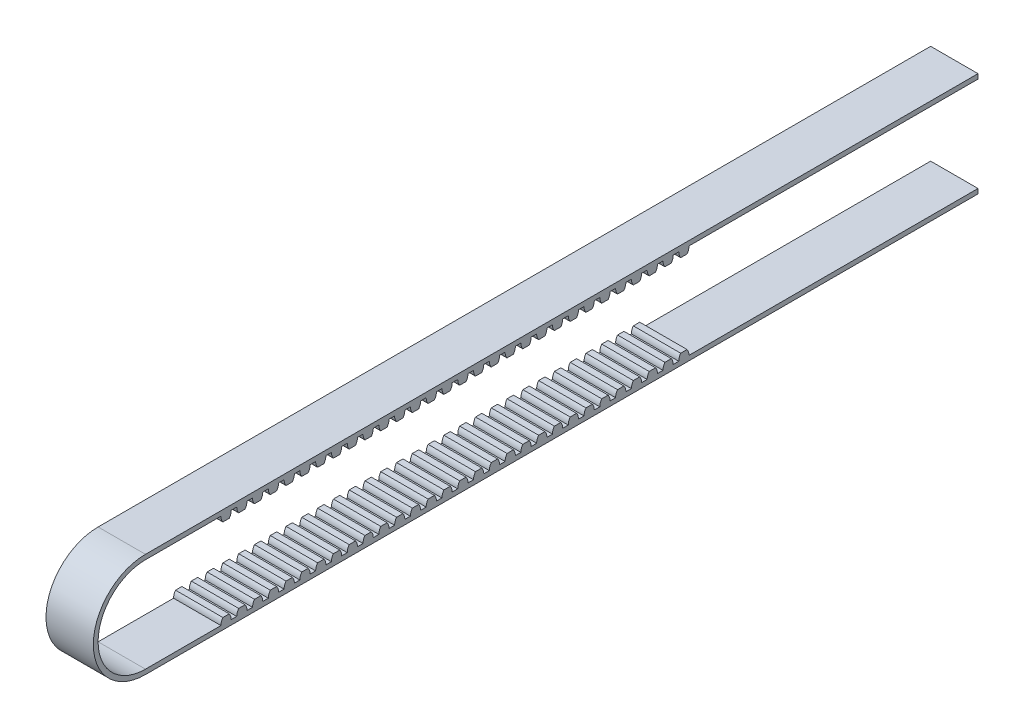
from build123d import *

# Parameters (mm, degrees)
SKETCH_1_W             = 6
SKETCH_1_H             = 0.6
EXTRUDE_1_DEPTH        = 100
EXTRUDE_2_DEPTH        = 6
PATTERN_LINEAR_1_COUNT = 30
PATTERN_LINEAR_1_PITCH = 2
EXTRUDE_3_DEPTH        = 6
MIRROR_1_COPY_1_DEPTH  = 6
MIRROR_1_COPY_2_DEPTH  = 6
MIRROR_1_COPY_3_DEPTH  = 6
MIRROR_1_COPY_4_DEPTH  = 6
MIRROR_1_COPY_5_DEPTH  = 6
MIRROR_1_COPY_6_DEPTH  = 6
MIRROR_1_COPY_7_DEPTH  = 6
MIRROR_1_COPY_8_DEPTH  = 6
MIRROR_1_COPY_9_DEPTH  = 6
MIRROR_1_COPY_10_DEPTH = 6
MIRROR_1_COPY_11_DEPTH = 6
MIRROR_1_COPY_12_DEPTH = 6
MIRROR_1_COPY_13_DEPTH = 6
MIRROR_1_COPY_14_DEPTH = 6
MIRROR_1_COPY_15_DEPTH = 6
MIRROR_1_COPY_16_DEPTH = 6
MIRROR_1_COPY_17_DEPTH = 6
MIRROR_1_COPY_18_DEPTH = 6
MIRROR_1_COPY_19_DEPTH = 6
MIRROR_1_COPY_20_DEPTH = 6
MIRROR_1_COPY_21_DEPTH = 6
MIRROR_1_COPY_22_DEPTH = 6
MIRROR_1_COPY_23_DEPTH = 6
MIRROR_1_COPY_24_DEPTH = 6
MIRROR_1_COPY_25_DEPTH = 6
MIRROR_1_COPY_26_DEPTH = 6
MIRROR_1_COPY_27_DEPTH = 6
MIRROR_1_COPY_28_DEPTH = 6
MIRROR_1_COPY_29_DEPTH = 6


with BuildPart() as part:
    # 草图1 → 凸台-拉伸1 (new body)
    with BuildSketch(Plane.XY):
        with Locations((3, 0.3)):
            Rectangle(SKETCH_1_W, SKETCH_1_H)
    extrude_1 = extrude(amount=EXTRUDE_1_DEPTH)

    # 草图2 → 凸台-拉伸2 (add)
    with BuildSketch(Plane(origin=(6, 0, 0), x_dir=(0, 0, -1), z_dir=(1, 0, 0))):
        with BuildLine():
            ThreePointArc((-95.914090338, 0), (-95.851247336, -0.399302595), (-95.668794088, -0.76))
            Line((-95.668794088, -0.76), (-94.859386588, -0.76))
            ThreePointArc((-94.859386588, -0.76), (-94.67693334, -0.399302595), (-94.614090338, 0))
            Line((-94.614090338, 0), (-95.914090338, 0))
        make_face()
    extrude_2 = extrude(amount=-EXTRUDE_2_DEPTH)

    # 阵列(线性)1: 凸台-拉伸2 ×30
    with Locations(*[(0, 0, -i * PATTERN_LINEAR_1_PITCH) for i in range(1, PATTERN_LINEAR_1_COUNT)]):
        add(extrude_2)

    # 草图3 → 凸台-拉伸3 (add)
    with BuildSketch(Plane(origin=(6, 0, 0), x_dir=(0, 0, -1), z_dir=(1, 0, 0))):
        with BuildLine():
            Line((-100, 0), (-105.478079639, 0))
            ThreePointArc((-105.478079639, 0), (-111.478079639, -6), (-105.478079639, -12))
            Line((-105.478079639, -12), (-93.443415231, -12))
            Line((-93.443415231, -12), (-93.443415231, -12.6))
            Line((-93.443415231, -12.6), (-105.478079639, -12.6))
            ThreePointArc((-105.478079639, -12.6), (-112.078079639, -6), (-105.478079639, 0.6))
            Line((-105.478079639, 0.6), (-100, 0.6))
            Line((-100, 0.6), (-100, 0))
        make_face()
    extrude_3 = extrude(amount=-EXTRUDE_3_DEPTH)

    # 镜向1: 凸台-拉伸3, 凸台-拉伸1, 凸台-拉伸2 across plane
    add(extrude_3.mirror(Plane.ZX.offset(-6)))
    add(extrude_1.mirror(Plane.ZX.offset(-6)))
    add(extrude_2.mirror(Plane.ZX.offset(-6)))

    # 镜向1 copy 1 sketch → 镜向1 copy 1 (add)
    with BuildSketch(Plane(origin=(6, -12, -2), x_dir=(0, 0, -1), z_dir=(1, 0, 0))):
        with BuildLine():
            ThreePointArc((-95.914090338, 0), (-95.851247336, 0.399302595), (-95.668794088, 0.76))
            Line((-95.668794088, 0.76), (-94.859386588, 0.76))
            ThreePointArc((-94.859386588, 0.76), (-94.67693334, 0.399302595), (-94.614090338, 0))
            Line((-94.614090338, 0), (-95.914090338, 0))
        make_face()
    extrude(amount=-MIRROR_1_COPY_1_DEPTH)

    # 镜向1 copy 2 sketch → 镜向1 copy 2 (add)
    with BuildSketch(Plane(origin=(6, -12, -4), x_dir=(0, 0, -1), z_dir=(1, 0, 0))):
        with BuildLine():
            ThreePointArc((-95.914090338, 0), (-95.851247336, 0.399302595), (-95.668794088, 0.76))
            Line((-95.668794088, 0.76), (-94.859386588, 0.76))
            ThreePointArc((-94.859386588, 0.76), (-94.67693334, 0.399302595), (-94.614090338, 0))
            Line((-94.614090338, 0), (-95.914090338, 0))
        make_face()
    extrude(amount=-MIRROR_1_COPY_2_DEPTH)

    # 镜向1 copy 3 sketch → 镜向1 copy 3 (add)
    with BuildSketch(Plane(origin=(6, -12, -6), x_dir=(0, 0, -1), z_dir=(1, 0, 0))):
        with BuildLine():
            ThreePointArc((-95.914090338, 0), (-95.851247336, 0.399302595), (-95.668794088, 0.76))
            Line((-95.668794088, 0.76), (-94.859386588, 0.76))
            ThreePointArc((-94.859386588, 0.76), (-94.67693334, 0.399302595), (-94.614090338, 0))
            Line((-94.614090338, 0), (-95.914090338, 0))
        make_face()
    extrude(amount=-MIRROR_1_COPY_3_DEPTH)

    # 镜向1 copy 4 sketch → 镜向1 copy 4 (add)
    with BuildSketch(Plane(origin=(6, -12, -8), x_dir=(0, 0, -1), z_dir=(1, 0, 0))):
        with BuildLine():
            ThreePointArc((-95.914090338, 0), (-95.851247336, 0.399302595), (-95.668794088, 0.76))
            Line((-95.668794088, 0.76), (-94.859386588, 0.76))
            ThreePointArc((-94.859386588, 0.76), (-94.67693334, 0.399302595), (-94.614090338, 0))
            Line((-94.614090338, 0), (-95.914090338, 0))
        make_face()
    extrude(amount=-MIRROR_1_COPY_4_DEPTH)

    # 镜向1 copy 5 sketch → 镜向1 copy 5 (add)
    with BuildSketch(Plane(origin=(6, -12, -10), x_dir=(0, 0, -1), z_dir=(1, 0, 0))):
        with BuildLine():
            ThreePointArc((-95.914090338, 0), (-95.851247336, 0.399302595), (-95.668794088, 0.76))
            Line((-95.668794088, 0.76), (-94.859386588, 0.76))
            ThreePointArc((-94.859386588, 0.76), (-94.67693334, 0.399302595), (-94.614090338, 0))
            Line((-94.614090338, 0), (-95.914090338, 0))
        make_face()
    extrude(amount=-MIRROR_1_COPY_5_DEPTH)

    # 镜向1 copy 6 sketch → 镜向1 copy 6 (add)
    with BuildSketch(Plane(origin=(6, -12, -12), x_dir=(0, 0, -1), z_dir=(1, 0, 0))):
        with BuildLine():
            ThreePointArc((-95.914090338, 0), (-95.851247336, 0.399302595), (-95.668794088, 0.76))
            Line((-95.668794088, 0.76), (-94.859386588, 0.76))
            ThreePointArc((-94.859386588, 0.76), (-94.67693334, 0.399302595), (-94.614090338, 0))
            Line((-94.614090338, 0), (-95.914090338, 0))
        make_face()
    extrude(amount=-MIRROR_1_COPY_6_DEPTH)

    # 镜向1 copy 7 sketch → 镜向1 copy 7 (add)
    with BuildSketch(Plane(origin=(6, -12, -14), x_dir=(0, 0, -1), z_dir=(1, 0, 0))):
        with BuildLine():
            ThreePointArc((-95.914090338, 0), (-95.851247336, 0.399302595), (-95.668794088, 0.76))
            Line((-95.668794088, 0.76), (-94.859386588, 0.76))
            ThreePointArc((-94.859386588, 0.76), (-94.67693334, 0.399302595), (-94.614090338, 0))
            Line((-94.614090338, 0), (-95.914090338, 0))
        make_face()
    extrude(amount=-MIRROR_1_COPY_7_DEPTH)

    # 镜向1 copy 8 sketch → 镜向1 copy 8 (add)
    with BuildSketch(Plane(origin=(6, -12, -16), x_dir=(0, 0, -1), z_dir=(1, 0, 0))):
        with BuildLine():
            ThreePointArc((-95.914090338, 0), (-95.851247336, 0.399302595), (-95.668794088, 0.76))
            Line((-95.668794088, 0.76), (-94.859386588, 0.76))
            ThreePointArc((-94.859386588, 0.76), (-94.67693334, 0.399302595), (-94.614090338, 0))
            Line((-94.614090338, 0), (-95.914090338, 0))
        make_face()
    extrude(amount=-MIRROR_1_COPY_8_DEPTH)

    # 镜向1 copy 9 sketch → 镜向1 copy 9 (add)
    with BuildSketch(Plane(origin=(6, -12, -18), x_dir=(0, 0, -1), z_dir=(1, 0, 0))):
        with BuildLine():
            ThreePointArc((-95.914090338, 0), (-95.851247336, 0.399302595), (-95.668794088, 0.76))
            Line((-95.668794088, 0.76), (-94.859386588, 0.76))
            ThreePointArc((-94.859386588, 0.76), (-94.67693334, 0.399302595), (-94.614090338, 0))
            Line((-94.614090338, 0), (-95.914090338, 0))
        make_face()
    extrude(amount=-MIRROR_1_COPY_9_DEPTH)

    # 镜向1 copy 10 sketch → 镜向1 copy 10 (add)
    with BuildSketch(Plane(origin=(6, -12, -20), x_dir=(0, 0, -1), z_dir=(1, 0, 0))):
        with BuildLine():
            ThreePointArc((-95.914090338, 0), (-95.851247336, 0.399302595), (-95.668794088, 0.76))
            Line((-95.668794088, 0.76), (-94.859386588, 0.76))
            ThreePointArc((-94.859386588, 0.76), (-94.67693334, 0.399302595), (-94.614090338, 0))
            Line((-94.614090338, 0), (-95.914090338, 0))
        make_face()
    extrude(amount=-MIRROR_1_COPY_10_DEPTH)

    # 镜向1 copy 11 sketch → 镜向1 copy 11 (add)
    with BuildSketch(Plane(origin=(6, -12, -22), x_dir=(0, 0, -1), z_dir=(1, 0, 0))):
        with BuildLine():
            ThreePointArc((-95.914090338, 0), (-95.851247336, 0.399302595), (-95.668794088, 0.76))
            Line((-95.668794088, 0.76), (-94.859386588, 0.76))
            ThreePointArc((-94.859386588, 0.76), (-94.67693334, 0.399302595), (-94.614090338, 0))
            Line((-94.614090338, 0), (-95.914090338, 0))
        make_face()
    extrude(amount=-MIRROR_1_COPY_11_DEPTH)

    # 镜向1 copy 12 sketch → 镜向1 copy 12 (add)
    with BuildSketch(Plane(origin=(6, -12, -24), x_dir=(0, 0, -1), z_dir=(1, 0, 0))):
        with BuildLine():
            ThreePointArc((-95.914090338, 0), (-95.851247336, 0.399302595), (-95.668794088, 0.76))
            Line((-95.668794088, 0.76), (-94.859386588, 0.76))
            ThreePointArc((-94.859386588, 0.76), (-94.67693334, 0.399302595), (-94.614090338, 0))
            Line((-94.614090338, 0), (-95.914090338, 0))
        make_face()
    extrude(amount=-MIRROR_1_COPY_12_DEPTH)

    # 镜向1 copy 13 sketch → 镜向1 copy 13 (add)
    with BuildSketch(Plane(origin=(6, -12, -26), x_dir=(0, 0, -1), z_dir=(1, 0, 0))):
        with BuildLine():
            ThreePointArc((-95.914090338, 0), (-95.851247336, 0.399302595), (-95.668794088, 0.76))
            Line((-95.668794088, 0.76), (-94.859386588, 0.76))
            ThreePointArc((-94.859386588, 0.76), (-94.67693334, 0.399302595), (-94.614090338, 0))
            Line((-94.614090338, 0), (-95.914090338, 0))
        make_face()
    extrude(amount=-MIRROR_1_COPY_13_DEPTH)

    # 镜向1 copy 14 sketch → 镜向1 copy 14 (add)
    with BuildSketch(Plane(origin=(6, -12, -28), x_dir=(0, 0, -1), z_dir=(1, 0, 0))):
        with BuildLine():
            ThreePointArc((-95.914090338, 0), (-95.851247336, 0.399302595), (-95.668794088, 0.76))
            Line((-95.668794088, 0.76), (-94.859386588, 0.76))
            ThreePointArc((-94.859386588, 0.76), (-94.67693334, 0.399302595), (-94.614090338, 0))
            Line((-94.614090338, 0), (-95.914090338, 0))
        make_face()
    extrude(amount=-MIRROR_1_COPY_14_DEPTH)

    # 镜向1 copy 15 sketch → 镜向1 copy 15 (add)
    with BuildSketch(Plane(origin=(6, -12, -30), x_dir=(0, 0, -1), z_dir=(1, 0, 0))):
        with BuildLine():
            ThreePointArc((-95.914090338, 0), (-95.851247336, 0.399302595), (-95.668794088, 0.76))
            Line((-95.668794088, 0.76), (-94.859386588, 0.76))
            ThreePointArc((-94.859386588, 0.76), (-94.67693334, 0.399302595), (-94.614090338, 0))
            Line((-94.614090338, 0), (-95.914090338, 0))
        make_face()
    extrude(amount=-MIRROR_1_COPY_15_DEPTH)

    # 镜向1 copy 16 sketch → 镜向1 copy 16 (add)
    with BuildSketch(Plane(origin=(6, -12, -32), x_dir=(0, 0, -1), z_dir=(1, 0, 0))):
        with BuildLine():
            ThreePointArc((-95.914090338, 0), (-95.851247336, 0.399302595), (-95.668794088, 0.76))
            Line((-95.668794088, 0.76), (-94.859386588, 0.76))
            ThreePointArc((-94.859386588, 0.76), (-94.67693334, 0.399302595), (-94.614090338, 0))
            Line((-94.614090338, 0), (-95.914090338, 0))
        make_face()
    extrude(amount=-MIRROR_1_COPY_16_DEPTH)

    # 镜向1 copy 17 sketch → 镜向1 copy 17 (add)
    with BuildSketch(Plane(origin=(6, -12, -34), x_dir=(0, 0, -1), z_dir=(1, 0, 0))):
        with BuildLine():
            ThreePointArc((-95.914090338, 0), (-95.851247336, 0.399302595), (-95.668794088, 0.76))
            Line((-95.668794088, 0.76), (-94.859386588, 0.76))
            ThreePointArc((-94.859386588, 0.76), (-94.67693334, 0.399302595), (-94.614090338, 0))
            Line((-94.614090338, 0), (-95.914090338, 0))
        make_face()
    extrude(amount=-MIRROR_1_COPY_17_DEPTH)

    # 镜向1 copy 18 sketch → 镜向1 copy 18 (add)
    with BuildSketch(Plane(origin=(6, -12, -36), x_dir=(0, 0, -1), z_dir=(1, 0, 0))):
        with BuildLine():
            ThreePointArc((-95.914090338, 0), (-95.851247336, 0.399302595), (-95.668794088, 0.76))
            Line((-95.668794088, 0.76), (-94.859386588, 0.76))
            ThreePointArc((-94.859386588, 0.76), (-94.67693334, 0.399302595), (-94.614090338, 0))
            Line((-94.614090338, 0), (-95.914090338, 0))
        make_face()
    extrude(amount=-MIRROR_1_COPY_18_DEPTH)

    # 镜向1 copy 19 sketch → 镜向1 copy 19 (add)
    with BuildSketch(Plane(origin=(6, -12, -38), x_dir=(0, 0, -1), z_dir=(1, 0, 0))):
        with BuildLine():
            ThreePointArc((-95.914090338, 0), (-95.851247336, 0.399302595), (-95.668794088, 0.76))
            Line((-95.668794088, 0.76), (-94.859386588, 0.76))
            ThreePointArc((-94.859386588, 0.76), (-94.67693334, 0.399302595), (-94.614090338, 0))
            Line((-94.614090338, 0), (-95.914090338, 0))
        make_face()
    extrude(amount=-MIRROR_1_COPY_19_DEPTH)

    # 镜向1 copy 20 sketch → 镜向1 copy 20 (add)
    with BuildSketch(Plane(origin=(6, -12, -40), x_dir=(0, 0, -1), z_dir=(1, 0, 0))):
        with BuildLine():
            ThreePointArc((-95.914090338, 0), (-95.851247336, 0.399302595), (-95.668794088, 0.76))
            Line((-95.668794088, 0.76), (-94.859386588, 0.76))
            ThreePointArc((-94.859386588, 0.76), (-94.67693334, 0.399302595), (-94.614090338, 0))
            Line((-94.614090338, 0), (-95.914090338, 0))
        make_face()
    extrude(amount=-MIRROR_1_COPY_20_DEPTH)

    # 镜向1 copy 21 sketch → 镜向1 copy 21 (add)
    with BuildSketch(Plane(origin=(6, -12, -42), x_dir=(0, 0, -1), z_dir=(1, 0, 0))):
        with BuildLine():
            ThreePointArc((-95.914090338, 0), (-95.851247336, 0.399302595), (-95.668794088, 0.76))
            Line((-95.668794088, 0.76), (-94.859386588, 0.76))
            ThreePointArc((-94.859386588, 0.76), (-94.67693334, 0.399302595), (-94.614090338, 0))
            Line((-94.614090338, 0), (-95.914090338, 0))
        make_face()
    extrude(amount=-MIRROR_1_COPY_21_DEPTH)

    # 镜向1 copy 22 sketch → 镜向1 copy 22 (add)
    with BuildSketch(Plane(origin=(6, -12, -44), x_dir=(0, 0, -1), z_dir=(1, 0, 0))):
        with BuildLine():
            ThreePointArc((-95.914090338, 0), (-95.851247336, 0.399302595), (-95.668794088, 0.76))
            Line((-95.668794088, 0.76), (-94.859386588, 0.76))
            ThreePointArc((-94.859386588, 0.76), (-94.67693334, 0.399302595), (-94.614090338, 0))
            Line((-94.614090338, 0), (-95.914090338, 0))
        make_face()
    extrude(amount=-MIRROR_1_COPY_22_DEPTH)

    # 镜向1 copy 23 sketch → 镜向1 copy 23 (add)
    with BuildSketch(Plane(origin=(6, -12, -46), x_dir=(0, 0, -1), z_dir=(1, 0, 0))):
        with BuildLine():
            ThreePointArc((-95.914090338, 0), (-95.851247336, 0.399302595), (-95.668794088, 0.76))
            Line((-95.668794088, 0.76), (-94.859386588, 0.76))
            ThreePointArc((-94.859386588, 0.76), (-94.67693334, 0.399302595), (-94.614090338, 0))
            Line((-94.614090338, 0), (-95.914090338, 0))
        make_face()
    extrude(amount=-MIRROR_1_COPY_23_DEPTH)

    # 镜向1 copy 24 sketch → 镜向1 copy 24 (add)
    with BuildSketch(Plane(origin=(6, -12, -48), x_dir=(0, 0, -1), z_dir=(1, 0, 0))):
        with BuildLine():
            ThreePointArc((-95.914090338, 0), (-95.851247336, 0.399302595), (-95.668794088, 0.76))
            Line((-95.668794088, 0.76), (-94.859386588, 0.76))
            ThreePointArc((-94.859386588, 0.76), (-94.67693334, 0.399302595), (-94.614090338, 0))
            Line((-94.614090338, 0), (-95.914090338, 0))
        make_face()
    extrude(amount=-MIRROR_1_COPY_24_DEPTH)

    # 镜向1 copy 25 sketch → 镜向1 copy 25 (add)
    with BuildSketch(Plane(origin=(6, -12, -50), x_dir=(0, 0, -1), z_dir=(1, 0, 0))):
        with BuildLine():
            ThreePointArc((-95.914090338, 0), (-95.851247336, 0.399302595), (-95.668794088, 0.76))
            Line((-95.668794088, 0.76), (-94.859386588, 0.76))
            ThreePointArc((-94.859386588, 0.76), (-94.67693334, 0.399302595), (-94.614090338, 0))
            Line((-94.614090338, 0), (-95.914090338, 0))
        make_face()
    extrude(amount=-MIRROR_1_COPY_25_DEPTH)

    # 镜向1 copy 26 sketch → 镜向1 copy 26 (add)
    with BuildSketch(Plane(origin=(6, -12, -52), x_dir=(0, 0, -1), z_dir=(1, 0, 0))):
        with BuildLine():
            ThreePointArc((-95.914090338, 0), (-95.851247336, 0.399302595), (-95.668794088, 0.76))
            Line((-95.668794088, 0.76), (-94.859386588, 0.76))
            ThreePointArc((-94.859386588, 0.76), (-94.67693334, 0.399302595), (-94.614090338, 0))
            Line((-94.614090338, 0), (-95.914090338, 0))
        make_face()
    extrude(amount=-MIRROR_1_COPY_26_DEPTH)

    # 镜向1 copy 27 sketch → 镜向1 copy 27 (add)
    with BuildSketch(Plane(origin=(6, -12, -54), x_dir=(0, 0, -1), z_dir=(1, 0, 0))):
        with BuildLine():
            ThreePointArc((-95.914090338, 0), (-95.851247336, 0.399302595), (-95.668794088, 0.76))
            Line((-95.668794088, 0.76), (-94.859386588, 0.76))
            ThreePointArc((-94.859386588, 0.76), (-94.67693334, 0.399302595), (-94.614090338, 0))
            Line((-94.614090338, 0), (-95.914090338, 0))
        make_face()
    extrude(amount=-MIRROR_1_COPY_27_DEPTH)

    # 镜向1 copy 28 sketch → 镜向1 copy 28 (add)
    with BuildSketch(Plane(origin=(6, -12, -56), x_dir=(0, 0, -1), z_dir=(1, 0, 0))):
        with BuildLine():
            ThreePointArc((-95.914090338, 0), (-95.851247336, 0.399302595), (-95.668794088, 0.76))
            Line((-95.668794088, 0.76), (-94.859386588, 0.76))
            ThreePointArc((-94.859386588, 0.76), (-94.67693334, 0.399302595), (-94.614090338, 0))
            Line((-94.614090338, 0), (-95.914090338, 0))
        make_face()
    extrude(amount=-MIRROR_1_COPY_28_DEPTH)

    # 镜向1 copy 29 sketch → 镜向1 copy 29 (add)
    with BuildSketch(Plane(origin=(6, -12, -58), x_dir=(0, 0, -1), z_dir=(1, 0, 0))):
        with BuildLine():
            ThreePointArc((-95.914090338, 0), (-95.851247336, 0.399302595), (-95.668794088, 0.76))
            Line((-95.668794088, 0.76), (-94.859386588, 0.76))
            ThreePointArc((-94.859386588, 0.76), (-94.67693334, 0.399302595), (-94.614090338, 0))
            Line((-94.614090338, 0), (-95.914090338, 0))
        make_face()
    extrude(amount=-MIRROR_1_COPY_29_DEPTH)


solid = part.part
